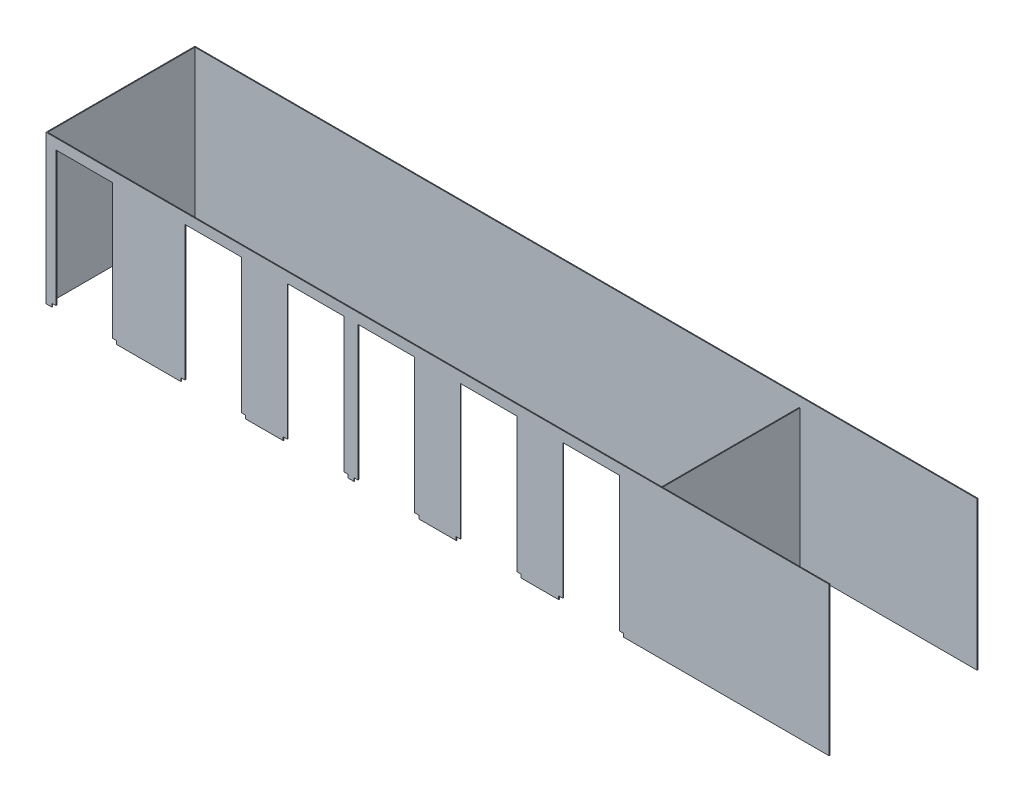
from build123d import *

# Parameters (mm, degrees)
SKETCH1_W           = 12.7
SKETCH1_H           = 2095.5
BOSS_EXTRUDE1_DEPTH = 2266.95
CUT_EXTRUDE2_DEPTH  = 12.7


with BuildPart() as part:
    # Sketch1 → Boss-Extrude1 (new body)
    with BuildSketch(Plane(origin=(0, 0, 0), x_dir=(1, 0, 0), z_dir=(0, 1, 0))):
        Polygon((11988.8, 2311.4), (11988.8, 2298.7), (50.8, 2298.7), (50.8, 50.8), (11988.8, 50.8), (11988.8, 38.1), (38.1, 38.1), (38.1, 2311.4), align=None)
        with Locations((9429.75, 1098.55)):
            Rectangle(SKETCH1_W, SKETCH1_H)
    extrude(amount=BOSS_EXTRUDE1_DEPTH)

    # Sketch2 → Cut-Extrude2 (cut)
    with BuildSketch(Plane.XY.offset(-38.1)):
        Polygon((190.5, 50.8), (127, 50.8), (127, 0), (1117.6, 0), (1117.6, 50.8), (1054.1, 50.8), (1054.1, 2108.2), (190.5, 2108.2), align=None)
        Polygon((2095.5, 50.8), (2095.5, 0), (3086.1, 0), (3086.1, 50.8), (3022.6, 50.8), (3022.6, 2108.2), (2159, 2108.2), (2159, 50.8), align=None)
        Polygon((3657.6, 50.8), (3657.6, 0), (4648.2, 0), (4648.2, 50.8), (4584.7, 50.8), (4584.7, 2108.2), (3721.1, 2108.2), (3721.1, 50.8), align=None)
        Polygon((4737.1, 50.8), (4737.1, 0), (5727.7, 0), (5727.7, 50.8), (5664.2, 50.8), (5664.2, 2108.2), (4800.6, 2108.2), (4800.6, 50.8), align=None)
        Polygon((6299.2, 50.8), (6299.2, 0), (7289.8, 0), (7289.8, 50.8), (7226.3, 50.8), (7226.3, 2108.2), (6362.7, 2108.2), (6362.7, 50.8), align=None)
        Polygon((7861.3, 50.8), (7861.3, 0), (8851.9, 0), (8851.9, 50.8), (8788.4, 50.8), (8788.4, 2108.2), (7924.8, 2108.2), (7924.8, 50.8), align=None)
    extrude(amount=-CUT_EXTRUDE2_DEPTH, mode=Mode.SUBTRACT)


solid = part.part
